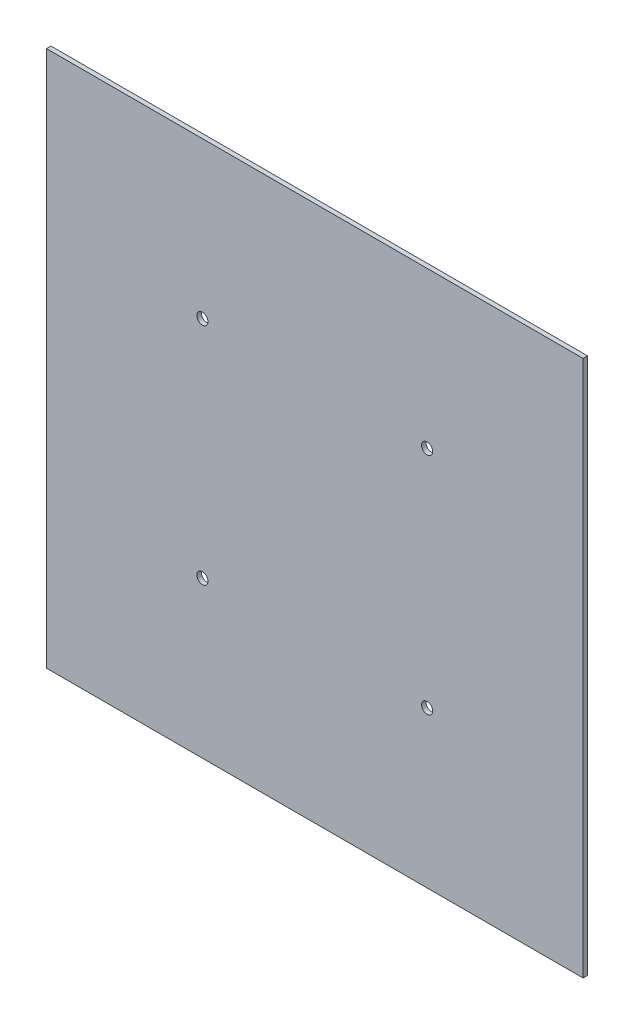
from build123d import *

# Parameters (mm, degrees)
SKETCH1_W           = 304.8
SKETCH1_H           = 304.8
SKETCH1_R           = 3.175
BOSS_EXTRUDE1_DEPTH = 2.54


with BuildPart() as part:
    # Sketch1 → Boss-Extrude1 (new body)
    with BuildSketch(Plane.XY):
        with Locations((152.4, 152.4)):
            Rectangle(SKETCH1_W, SKETCH1_H)
        with Locations((88.575, 216.225)):
            Circle(SKETCH1_R, mode=Mode.SUBTRACT)
        with Locations((88.575, 88.575)):
            Circle(SKETCH1_R, mode=Mode.SUBTRACT)
        with Locations((216.225, 88.575)):
            Circle(SKETCH1_R, mode=Mode.SUBTRACT)
        with Locations((216.225, 216.225)):
            Circle(SKETCH1_R, mode=Mode.SUBTRACT)
    extrude(amount=BOSS_EXTRUDE1_DEPTH)


solid = part.part
